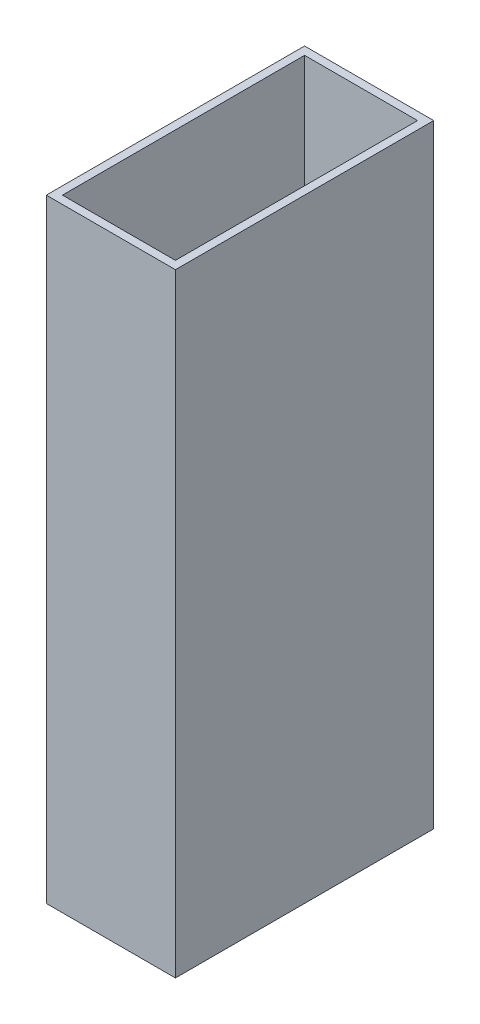
from build123d import *

# Parameters (mm, degrees)
SKETCH1_W           = 25.4
SKETCH1_H           = 50.8
SKETCH1_W_2         = 22.225
SKETCH1_H_2         = 47.625
BOSS_EXTRUDE1_DEPTH = 120.65


with BuildPart() as part:
    # Sketch1 → Boss-Extrude1 (new body)
    with BuildSketch(Plane(origin=(0, 0, 0), x_dir=(1, 0, 0), z_dir=(0, 1, 0))):
        Rectangle(SKETCH1_W, SKETCH1_H)
        Rectangle(SKETCH1_W_2, SKETCH1_H_2, mode=Mode.SUBTRACT)
    extrude(amount=BOSS_EXTRUDE1_DEPTH)


solid = part.part
